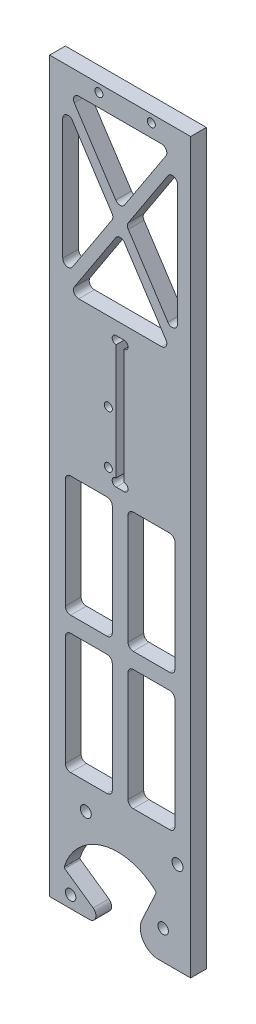
from build123d import *

# Parameters (mm, degrees)
SKETCH_1_W            = 67
SKETCH_1_H            = 30
EXTRUDE_1_DEPTH       = 6
SKETCH_3_R            = 11.5
CUT_EXTRUDE_1_DEPTH   = 7
CUT_EXTRUDE_2_DEPTH   = 35
EXTRUDE_2_DEPTH       = 6
FILLET_1_R            = 2.5
FILLET_3_R            = 0.5
FILLET_4_R            = 7
SKETCH_6_R            = 2
CUT_EXTRUDE_3_DEPTH   = 7
EXTRUDE_3_DEPTH       = 6
CUT_EXTRUDE_4_DEPTH   = 7
EXTRUDE_4_DEPTH       = 6
SKETCH_10_R           = 2.1
CUT_EXTRUDE_5_DEPTH   = 7
FILLET_5_R            = 5
SKETCH_11_R           = 1.6
CUT_EXTRUDE_6_DEPTH   = 7
CUT_EXTRUDE_7_DEPTH   = 10
FILLET_6_R            = 2
SKETCH_13_OUTSIDE_W   = 121.737
SKETCH_13_OUTSIDE_H   = 129.266
SKETCH_13_OUTSIDE_W_2 = 53.782400736
SKETCH_13_OUTSIDE_H_2 = 120
CUT_EXTRUDE_8_DEPTH   = 10
EXTRUDE_5_DEPTH       = 6
SKETCH_15_W           = 53.782400736
SKETCH_15_H           = 178
EXTRUDE_6_DEPTH       = 6
SKETCH_16_R           = 1.525
CUT_EXTRUDE_9_DEPTH   = 10
SKETCH_17_W           = 3.06
SKETCH_17_H           = 50.06
CUT_EXTRUDE_10_DEPTH  = 6
SKETCH_18_R           = 1.505
CUT_EXTRUDE_11_DEPTH  = 6
SKETCH_19_R           = 1.525
CUT_EXTRUDE_12_DEPTH  = 6
SKETCH_20_W           = 17.891200368
SKETCH_20_H           = 45.985
CUT_EXTRUDE_13_DEPTH  = 10
FILLET_7_R            = 2


with BuildPart() as part:
    # 草图1 → 凸台-拉伸1 (new body)
    with BuildSketch(Plane.XY):
        Rectangle(SKETCH_1_W, SKETCH_1_H)
    extrude(amount=EXTRUDE_1_DEPTH)

    # 草图3 → 切除-拉伸1 (cut, through all)
    with BuildSketch(Plane.XY.offset(6)):
        with Locations((0.155997342, -18.5)):
            Circle(SKETCH_3_R)
    extrude(amount=-CUT_EXTRUDE_1_DEPTH, mode=Mode.SUBTRACT)

    # 草图4 → 切除-拉伸2 (cut)
    with BuildSketch(Plane.XY.offset(6)):
        with BuildLine():
            Line((14.951296016, -3.246749948), (0.155997342, -34.975370344))
            Line((0.155997342, -34.975370344), (0.155997342, -27))
            Line((0.155997342, -27), (-20.283732192, -12.687947301))
            ThreePointArc((-20.283732192, -12.687947301), (-5.343907366, 2.025923809), (14.951296016, -3.246749948))
        make_face()
    extrude(amount=-CUT_EXTRUDE_2_DEPTH, mode=Mode.SUBTRACT)

    # 草图5 → 凸台-拉伸2 (add)
    with BuildSketch(Plane.XY.offset(6)):
        Polygon((-16.981778738, -15), (-2.700298671, -25), (-33.5, -25), (-33.5, -15), align=None)
        Polygon((33.5, -15), (33.5, -25), (4.807588927, -25), (10.334473164, -13.147558505), align=None)
    extrude(amount=-EXTRUDE_2_DEPTH)

    # 圆角1
    fillet_1_edges = [part.edges().sort_by_distance(p)[0] for p in [
        (-2.700298671, -25, 3),
    ]]
    fillet(fillet_1_edges, radius=FILLET_1_R)

    # 圆角3
    fillet_3_edges = [part.edges().sort_by_distance(p)[0] for p in [
        (-20.283732192, -12.687947301, 3),
        (14.951296016, -3.246749948, 3),
    ]]
    fillet(fillet_3_edges, radius=FILLET_3_R)

    # 圆角4
    fillet_4_edges = [part.edges().sort_by_distance(p)[0] for p in [
        (4.807588927, -25, 3),
    ]]
    fillet(fillet_4_edges, radius=FILLET_4_R)

    # 草图6 → 切除-拉伸3 (cut, through all)
    with BuildSketch(Plane.XY.offset(6)):
        with Locations((17.505658254, -13.841257188)):
            Circle(SKETCH_6_R)
        with Locations((-17.782400736, -20.381512339)):
            Circle(SKETCH_6_R)
    extrude(amount=-CUT_EXTRUDE_3_DEPTH, mode=Mode.SUBTRACT)

    # 草图7 → 凸台-拉伸3 (add)
    with BuildSketch(Plane.XY.offset(6)):
        Polygon((60.5, 75), (14.5, 75), (-16.303792618, 15), (33.5, 15), align=None)
    extrude(amount=-EXTRUDE_3_DEPTH)

    # 草图8 → 切除-拉伸4 (cut, through all)
    with BuildSketch(Plane.XY.offset(6)):
        Polygon((-16.303792618, 15), (-33.5, -18.49498082), (-33.5, 15), align=None)
    extrude(amount=-CUT_EXTRUDE_4_DEPTH, mode=Mode.SUBTRACT)

    # 草图9 → 凸台-拉伸4 (add)
    with BuildSketch(Plane.XY.offset(6)):
        Polygon((60.5, 75), (33.5, -25), (33.5, 15), align=None)
    extrude(amount=-EXTRUDE_4_DEPTH)

    # 草图10 → 切除-拉伸5 (cut, through all)
    with BuildSketch(Plane.XY.offset(6)):
        with Locations((-12, 10)):
            Circle(SKETCH_10_R)
        with Locations((23, 10)):
            Circle(SKETCH_10_R)
    extrude(amount=-CUT_EXTRUDE_5_DEPTH, mode=Mode.SUBTRACT)

    # 圆角5
    fillet_5_edges = [part.edges().sort_by_distance(p)[0] for p in [
        (60.5, 75, 3),
        (14.5, 75, 3),
    ]]
    fillet(fillet_5_edges, radius=FILLET_5_R)

    # 草图11 → 切除-拉伸6 (cut, through all)
    with BuildSketch(Plane.XY.offset(6)):
        with Locations((42.500000039, 67)):
            Circle(SKETCH_11_R)
        with Locations((22.500000039, 67)):
            Circle(SKETCH_11_R)
    extrude(amount=-CUT_EXTRUDE_6_DEPTH, mode=Mode.SUBTRACT)

    # 草图12 → 切除-拉伸7 (cut)
    with BuildSketch(Plane.XY.offset(6)):
        Polygon((33.412019277, 64), (31.452414539, 20), (29.670955687, -20), (52.350955687, 64), align=None)
        Polygon((28.047412755, 55.924590701), (-1.630833947, 20), (26.447458252, 20), align=None)
        Polygon((14.473082867, 64), (-8.116365053, 20), (28.233189094, 64), align=None)
    extrude(amount=-CUT_EXTRUDE_7_DEPTH, mode=Mode.SUBTRACT)

    # 圆角6
    fillet_6_edges = [part.edges().sort_by_distance(p)[0] for p in [
        (29.670955687, -20, 3),
        (33.412019277, 64, 3),
        (52.350955687, 64, 3),
        (14.473082867, 64, 3),
        (28.233189094, 64, 3),
        (-8.116365053, 20, 3),
        (28.047412755, 55.924590701, 3),
        (26.447458252, 20, 3),
        (-1.630833947, 20, 3),
    ]]
    fillet(fillet_6_edges, radius=FILLET_6_R)

    # 草图13 outside → 切除-拉伸8 (cut)
    with BuildSketch(Plane.XY.offset(6)):
        with Locations((12.7355, 25)):
            Rectangle(SKETCH_13_OUTSIDE_W, SKETCH_13_OUTSIDE_H)
        with Locations((1.108799632, 35)):
            Rectangle(SKETCH_13_OUTSIDE_W_2, SKETCH_13_OUTSIDE_H_2, mode=Mode.SUBTRACT)
    extrude(amount=-CUT_EXTRUDE_8_DEPTH, mode=Mode.SUBTRACT)

    # 草图14 → 凸台-拉伸5 (add)
    with BuildSketch(Plane.XY.offset(6)):
        Polygon((-25.782400736, -3.462547587), (-25.782400736, 75), (28, 75), (28, 15), (-16.303792618, 15), align=None)
    extrude(amount=-EXTRUDE_5_DEPTH)

    # 草图15 → 凸台-拉伸6 (add)
    with BuildSketch(Plane.XY.offset(6)):
        with Locations((1.108799632, 164)):
            Rectangle(SKETCH_15_W, SKETCH_15_H)
    extrude(amount=-EXTRUDE_6_DEPTH)

    # 草图16 → 切除-拉伸9 (cut)
    with BuildSketch(Plane.XY.offset(6)):
        with Locations((-7, 250)):
            Circle(SKETCH_16_R)
        with Locations((13, 250)):
            Circle(SKETCH_16_R)
    extrude(amount=-CUT_EXTRUDE_9_DEPTH, mode=Mode.SUBTRACT)

    # 草图17 → 切除-拉伸10 (cut)
    with BuildSketch(Plane.XY.offset(6)):
        with Locations((1.108799632, 148)):
            Rectangle(SKETCH_17_W, SKETCH_17_H)
    extrude(amount=-CUT_EXTRUDE_10_DEPTH, mode=Mode.SUBTRACT)

    # 草图18 → 切除-拉伸11 (cut)
    with BuildSketch(Plane.XY.offset(6)):
        with Locations((2.638799632, 124.475)):
            Circle(SKETCH_18_R)
        with Locations((-0.421200368, 124.475)):
            Circle(SKETCH_18_R)
        with Locations((-0.421200368, 171.525)):
            Circle(SKETCH_18_R)
        with Locations((2.638799632, 171.525)):
            Circle(SKETCH_18_R)
    extrude(amount=-CUT_EXTRUDE_11_DEPTH, mode=Mode.SUBTRACT)

    # 草图19 → 切除-拉伸12 (cut)
    with BuildSketch(Plane.XY.offset(6)):
        with Locations((-3.391200368, 148)):
            Circle(SKETCH_19_R)
        with Locations((-3.391200368, 128)):
            Circle(SKETCH_19_R)
    extrude(amount=-CUT_EXTRUDE_12_DEPTH, mode=Mode.SUBTRACT)

    # 草图20 → 切除-拉伸13 (cut)
    with BuildSketch(Plane.XY.offset(6)):
        with Locations((13.054399816, 94.9775)):
            Rectangle(SKETCH_20_W, SKETCH_20_H)
        with Locations((13.054399816, 42.9925)):
            Rectangle(SKETCH_20_W, SKETCH_20_H)
        with Locations((-10.836800552, 42.9925)):
            Rectangle(SKETCH_20_W, SKETCH_20_H)
        with Locations((-10.836800552, 94.9775)):
            Rectangle(SKETCH_20_W, SKETCH_20_H)
        Polygon((1.108799632, 207.860027008), (-18.392920488, 178.03), (20.610519752, 178.03), align=None)
        Polygon((23, 241.345027008), (3.49827988, 211.515), (23, 181.684972992), align=None)
        Polygon((-20.782400736, 241.345027008), (-20.782400736, 181.684972992), (-1.280680616, 211.515), align=None)
        Polygon((-18.392920488, 245), (1.108799632, 215.169972992), (20.610519752, 245), align=None)
    extrude(amount=-CUT_EXTRUDE_13_DEPTH, mode=Mode.SUBTRACT)

    # 圆角7
    fillet_7_edges = [part.edges().sort_by_distance(p)[0] for p in [
        (4.108799632, 65.985, 3),
        (22, 65.985, 3),
        (22, 20, 3),
        (4.108799632, 20, 3),
        (-1.891200368, 65.985, 3),
        (-1.891200368, 20, 3),
        (-19.782400736, 20, 3),
        (-19.782400736, 65.985, 3),
        (-19.782400736, 71.985, 3),
        (-19.782400736, 117.97, 3),
        (-1.891200368, 117.97, 3),
        (-1.891200368, 71.985, 3),
        (1.108799632, 207.860027008, 3),
        (20.610519752, 178.03, 3),
        (-18.392920488, 178.03, 3),
        (-18.392920488, 245, 3),
        (20.610519752, 245, 3),
        (1.108799632, 215.169972992, 3),
        (-20.782400736, 181.684972992, 3),
        (-20.782400736, 241.345027008, 3),
        (-1.280680616, 211.515, 3),
        (3.49827988, 211.515, 3),
        (23, 241.345027008, 3),
        (23, 181.684972992, 3),
        (4.108799632, 117.97, 3),
        (22, 117.97, 3),
        (22, 71.985, 3),
        (4.108799632, 71.985, 3),
    ]]
    fillet(fillet_7_edges, radius=FILLET_7_R)


solid = part.part
